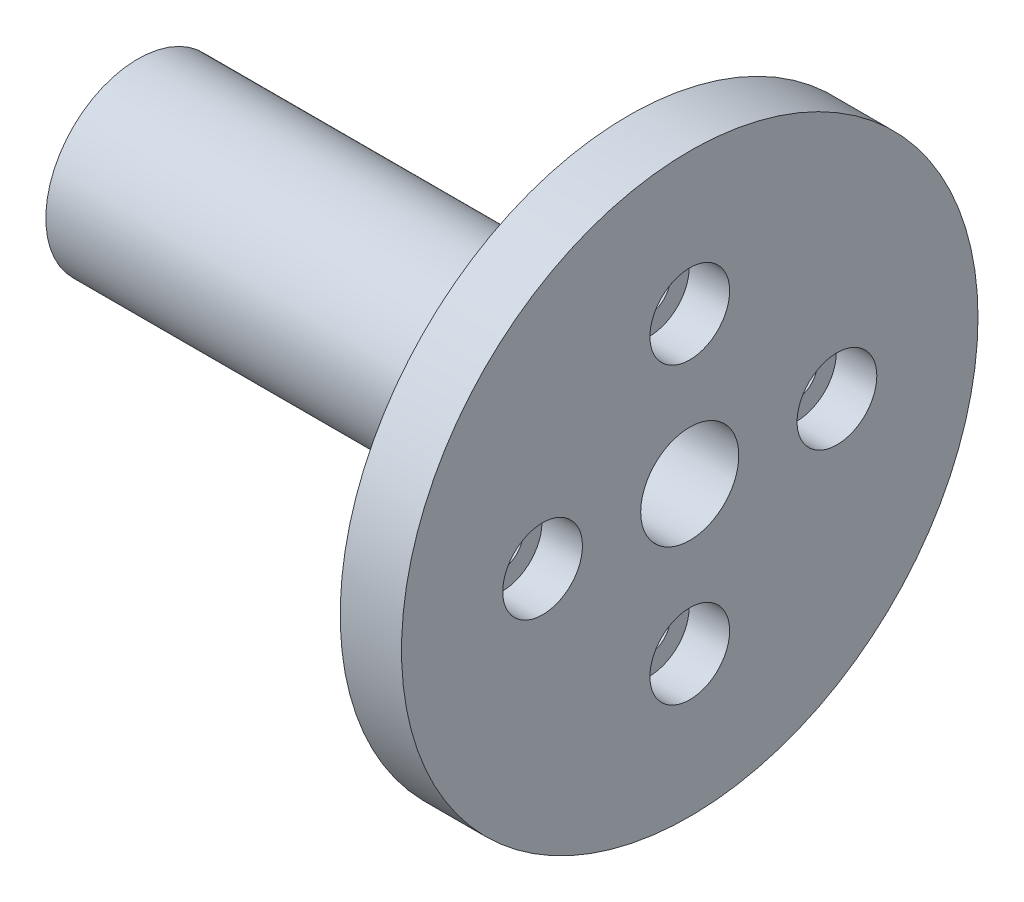
from build123d import *

# Parameters (mm, degrees)
SKETCH_2_R          = 1.7
CUT_EXTRUDE_1_DEPTH = 6
SKETCH_3_R          = 3.25
CUT_EXTRUDE_2_DEPTH = 3.3
SKETCH_4_R          = 4
CUT_EXTRUDE_3_DEPTH = 46


with BuildPart() as part:
    # 草图1 → 旋转1 (revolve)
    with BuildSketch(Plane(origin=(0, 0, 0), x_dir=(1, 0, 0), z_dir=(0, 1, 0))):
        Polygon((0, 0), (0, 16), (-5, 16), (-5, 0), (-45, 0), (-45, -7.5), (0, -7.5), align=None)
    revolve(axis=Axis((0, 0, 7.5), (-1, 0, 0)))

    # 草图2 → 切除-拉伸1 (cut, through all)
    with BuildSketch(Plane.ZY.offset(5)):
        with Locations((7.5, 12)):
            Circle(SKETCH_2_R)
        with Locations((19.5, 0)):
            Circle(SKETCH_2_R)
        with Locations((7.5, -12)):
            Circle(SKETCH_2_R)
        with Locations((-4.5, 0)):
            Circle(SKETCH_2_R)
    extrude(amount=-CUT_EXTRUDE_1_DEPTH, mode=Mode.SUBTRACT)

    # 草图3 → 切除-拉伸2 (cut)
    with BuildSketch(Plane(origin=(0, 0, 0), x_dir=(0, 0, -1), z_dir=(1, 0, 0))):
        with Locations((-7.5, 12)):
            Circle(SKETCH_3_R)
        with Locations((-19.5, 0)):
            Circle(SKETCH_3_R)
        with Locations((4.5, 0)):
            Circle(SKETCH_3_R)
        with Locations((-7.5, -12)):
            Circle(SKETCH_3_R)
    extrude(amount=-CUT_EXTRUDE_2_DEPTH, mode=Mode.SUBTRACT)

    # 草图4 → 切除-拉伸3 (cut, through all)
    with BuildSketch(Plane.ZY.offset(45)):
        with Locations((7.5, 0)):
            Circle(SKETCH_4_R)
    extrude(amount=-CUT_EXTRUDE_3_DEPTH, mode=Mode.SUBTRACT)


solid = part.part
